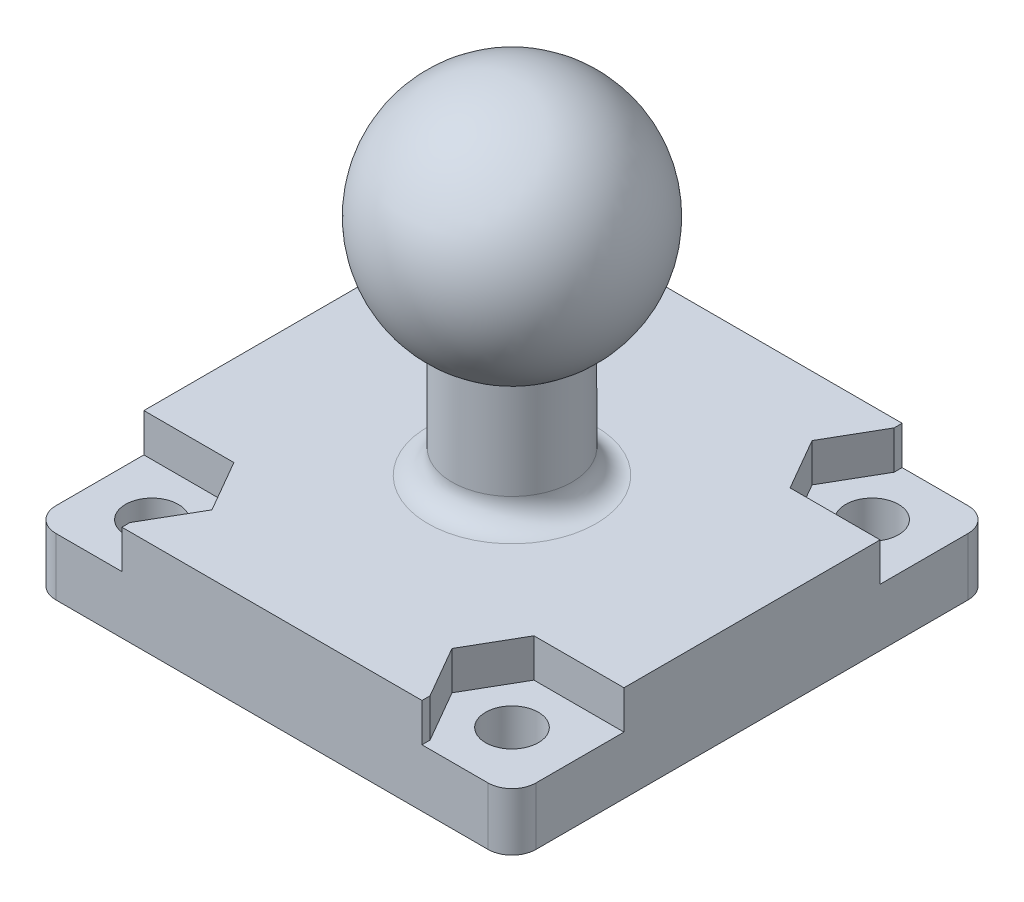
from build123d import *

# Parameters (mm, degrees)
ESQUISSE2_W             = 20
ESQUISSE2_H             = 20
BOSS_EXTRU_1_DEPTH      = 4
ENL_V_MAT_EXTRU_1_REACH = 6
ESQUISSE3_R             = 1.1
CONG_1_R                = 1
ENL_V_MAT_EXTRU_2_DEPTH = 1.6


with BuildPart() as part:
    # Esquisse1 → Révolution1 (revolve)
    with BuildSketch(Plane.XY):
        with BuildLine():
            Line((-2.5, -4.330127019), (-2.5, -9.330127019))
            Line((-2.5, -9.330127019), (0, -9.330127019))
            Line((0, -9.330127019), (0, 5))
            ThreePointArc((0, 5), (-4.829629131, 1.294095226), (-2.5, -4.330127019))
        make_face()
    revolve(axis=Axis((0, -9.330127019, 0), (0, 1, 0)))

    # Esquisse2 → Boss.-Extru.1 (add)
    with BuildSketch(Plane.XZ.offset(9.330127019)):
        Rectangle(ESQUISSE2_W, ESQUISSE2_H)
    extrude(amount=BOSS_EXTRU_1_DEPTH)

    # Esquisse3 → Enlèv. mat.-Extru.1 (cut, up to next)
    with BuildSketch(Plane(origin=(0, -9.330127019, 0), x_dir=(1, 0, 0), z_dir=(0, 1, 0)), mode=Mode.PRIVATE) as enl_v_mat_extru_1_sk1:
        with Locations(Location((7.5, -7.5, 0), (0, 0, 180))):  # turned: the seam where the file's is
            Circle(ESQUISSE3_R)
    enl_v_mat_extru_1_tool1 = extrude(enl_v_mat_extru_1_sk1.sketch, amount=-ENL_V_MAT_EXTRU_1_REACH, mode=Mode.PRIVATE) & part.part
    add(enl_v_mat_extru_1_tool1.solids().sort_by_distance((7.5, -9.330127, 7.5))[0], mode=Mode.SUBTRACT)
    # Esquisse3 → Enlèv. mat.-Extru.1 (cut, up to next)
    with BuildSketch(Plane(origin=(0, -9.330127019, 0), x_dir=(1, 0, 0), z_dir=(0, 1, 0)), mode=Mode.PRIVATE) as enl_v_mat_extru_1_sk2:
        with Locations(Location((7.5, 7.5, 0), (0, 0, 180))):  # turned: the seam where the file's is
            Circle(ESQUISSE3_R)
    enl_v_mat_extru_1_tool2 = extrude(enl_v_mat_extru_1_sk2.sketch, amount=-ENL_V_MAT_EXTRU_1_REACH, mode=Mode.PRIVATE) & part.part
    add(enl_v_mat_extru_1_tool2.solids().sort_by_distance((7.5, -9.330127, -7.5))[0], mode=Mode.SUBTRACT)
    # Esquisse3 → Enlèv. mat.-Extru.1 (cut, up to next)
    with BuildSketch(Plane(origin=(0, -9.330127019, 0), x_dir=(1, 0, 0), z_dir=(0, 1, 0)), mode=Mode.PRIVATE) as enl_v_mat_extru_1_sk3:
        with Locations(Location((-7.5, 7.5, 0), (0, 0, 180))):  # turned: the seam where the file's is
            Circle(ESQUISSE3_R)
    enl_v_mat_extru_1_tool3 = extrude(enl_v_mat_extru_1_sk3.sketch, amount=-ENL_V_MAT_EXTRU_1_REACH, mode=Mode.PRIVATE) & part.part
    add(enl_v_mat_extru_1_tool3.solids().sort_by_distance((-7.5, -9.330127, -7.5))[0], mode=Mode.SUBTRACT)
    # Esquisse3 → Enlèv. mat.-Extru.1 (cut, up to next)
    with BuildSketch(Plane(origin=(0, -9.330127019, 0), x_dir=(1, 0, 0), z_dir=(0, 1, 0)), mode=Mode.PRIVATE) as enl_v_mat_extru_1_sk4:
        with Locations(Location((-7.5, -7.5, 0), (0, 0, 180))):  # turned: the seam where the file's is
            Circle(ESQUISSE3_R)
    enl_v_mat_extru_1_tool4 = extrude(enl_v_mat_extru_1_sk4.sketch, amount=-ENL_V_MAT_EXTRU_1_REACH, mode=Mode.PRIVATE) & part.part
    add(enl_v_mat_extru_1_tool4.solids().sort_by_distance((-7.5, -9.330127, 7.5))[0], mode=Mode.SUBTRACT)

    # Congé1
    cong_1_edges = [part.edges().sort_by_distance(p)[0] for p in [
        (-10, -11.330127019, -10),
        (10, -11.330127019, -10),
        (10, -11.330127019, 10),
        (2.5, -9.330127019, 0),
        (-10, -11.330127019, 10),
    ]]
    fillet(cong_1_edges, radius=CONG_1_R)

    # Esquisse4 → Enlèv. mat.-Extru.2 (cut)
    with BuildSketch(Plane(origin=(0, -9.330127019, 0), x_dir=(1, 0, 0), z_dir=(0, 1, 0))):
        Polygon((12.747875309, 12.760132689), (12.747875309, 5.334936491), (6.25, 5.334936491), (5, 7.5), (6.25, 9.665063509), (6.25, 12.760132689), align=None)
        Polygon((6.25, -13.48135855), (14.143640295, -13.48135855), (14.143640295, -5.334936491), (6.25, -5.334936491), (5, -7.5), (6.25, -9.665063509), align=None)
        Polygon((-14.237362356, -5.334936491), (-6.25, -5.334936491), (-5, -7.5), (-6.25, -9.665063509), (-6.25, -13.439575721), (-14.237362356, -13.439575721), align=None)
        Polygon((-6.25, 12.760132689), (-6.25, 9.665063509), (-5, 7.5), (-6.25, 5.334936491), (-8.75, 5.334936491), (-15.525855113, 5.334936491), (-15.525855113, 12.760132689), align=None)
    extrude(amount=-ENL_V_MAT_EXTRU_2_DEPTH, mode=Mode.SUBTRACT)


solid = part.part
